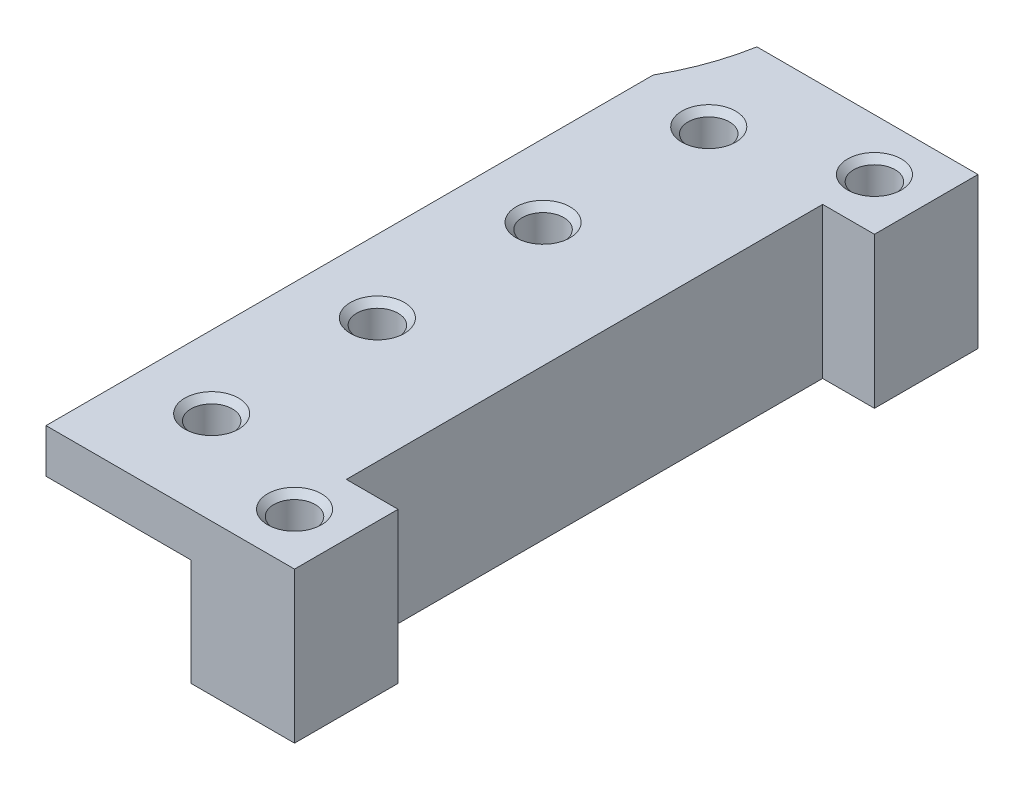
from build123d import *

# Parameters (mm, degrees)
IZIM3_W                                          = 3.5
IZIM3_H                                          = 23
IZIM3_H_2                                        = 5
IZIM3_W_2                                        = 2.5
Y_KSEKLIK_EKSTR_ZYON3_DEPTH                      = 8.28
IZIM4_W                                          = 7
IZIM4_H                                          = 5.16
KES_EKSTR_ZYON1_DEPTH                            = 34
IZIM11_W                                         = 12
IZIM11_H                                         = 33
KES_EKSTR_ZYON2_DEPTH                            = 1
M2_D_Z_BA_L_MAKINE_VIDAS_IN_HAV_A_DE_D           = 2
M2_D_Z_BA_L_MAKINE_VIDAS_IN_HAV_A_DE_CSINK_D     = 2.6
M2_D_Z_BA_L_MAKINE_VIDAS_IN_HAV_A_DE_CSINK_ANGLE = 90


with BuildPart() as part:
    # Çizim3 → Yükseklik-Ekstrüzyon3 (new body)
    with BuildSketch(Plane(origin=(0, 0, 0), x_dir=(1, 0, 0), z_dir=(0, 1, 0))):
        with BuildLine():
            Line((16, 6.5), (16, 11.5))
            Line((16, 11.5), (11.324751653, 11.5))
            ThreePointArc((11.324751653, 11.5), (10.819882158, 9.603828792), (10, 7.821091654))
            Line((10, 7.821091654), (10, -21.5))
            Line((10, -21.5), (16, -21.5))
            Line((16, -21.5), (16, -16.5))
            Line((16, -16.5), (16, 6.5))
        make_face()
        with Locations((17.75, -5)):
            Rectangle(IZIM3_W, IZIM3_H)
        with Locations((17.75, 9)):
            Rectangle(IZIM3_W, IZIM3_H_2)
        with Locations((20.75, 9)):
            Rectangle(IZIM3_W_2, IZIM3_H_2)
        with Locations((17.75, -19)):
            Rectangle(IZIM3_W, IZIM3_H_2)
        with Locations((20.75, -19)):
            Rectangle(IZIM3_W_2, IZIM3_H_2)
    extrude(amount=Y_KSEKLIK_EKSTR_ZYON3_DEPTH)

    # Çizim4 → Kes-Ekstrüzyon1 (cut, through all)
    with BuildSketch(Plane.XY.offset(21.5)):
        with Locations((13.5, 2.58)):
            Rectangle(IZIM4_W, IZIM4_H)
    extrude(amount=-KES_EKSTR_ZYON1_DEPTH, mode=Mode.SUBTRACT)

    # Çizim11 → Kes-Ekstrüzyon2 (cut)
    with BuildSketch(Plane(origin=(0, 8.28, 0), x_dir=(1, 0, 0), z_dir=(0, 1, 0))):
        with Locations((16, -5)):
            Rectangle(IZIM11_W, IZIM11_H)
    extrude(amount=-KES_EKSTR_ZYON2_DEPTH, mode=Mode.SUBTRACT)

    # M2 Düz Başlı Makine Vidası İçin Havşa_ DEĞİŞTİREBİLİRİZ (through all)
    with Locations(Plane(origin=(19.5, 7.28, 19), x_dir=(0, 0, 1), z_dir=(0, 1, 0))):
        with Locations((0, 0), (-28, 0), (-2, -6), (-10, -6), (-18, -6), (-26, -6)):
            CounterSinkHole(M2_D_Z_BA_L_MAKINE_VIDAS_IN_HAV_A_DE_D / 2, M2_D_Z_BA_L_MAKINE_VIDAS_IN_HAV_A_DE_CSINK_D / 2, counter_sink_angle=M2_D_Z_BA_L_MAKINE_VIDAS_IN_HAV_A_DE_CSINK_ANGLE)


solid = part.part
